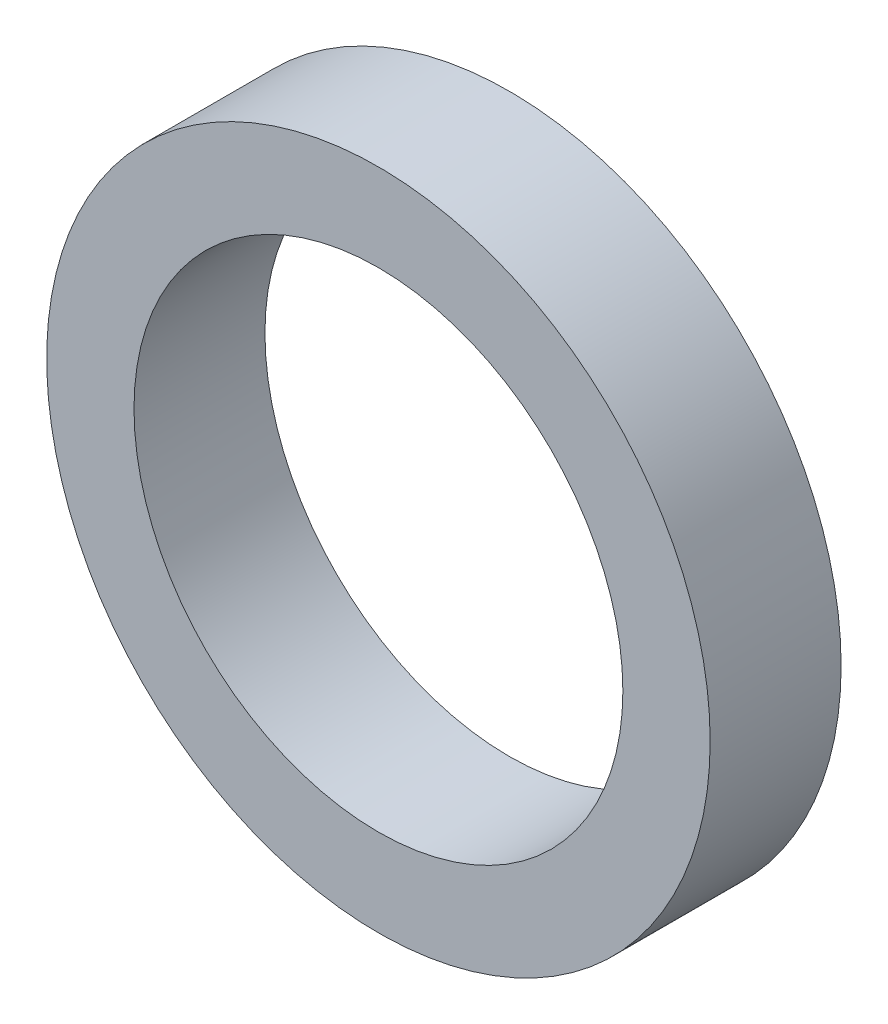
from build123d import *

# Parameters (mm, degrees)
SKETCH1_R           = 4.826
SKETCH1_R_2         = 3.556
BOSS_EXTRUDE1_DEPTH = 1.905


with BuildPart() as part:
    # Sketch1 → Boss-Extrude1 (new body)
    with BuildSketch(Plane.XY):
        Circle(SKETCH1_R)
        Circle(SKETCH1_R_2, mode=Mode.SUBTRACT)
    extrude(amount=BOSS_EXTRUDE1_DEPTH)


solid = part.part
